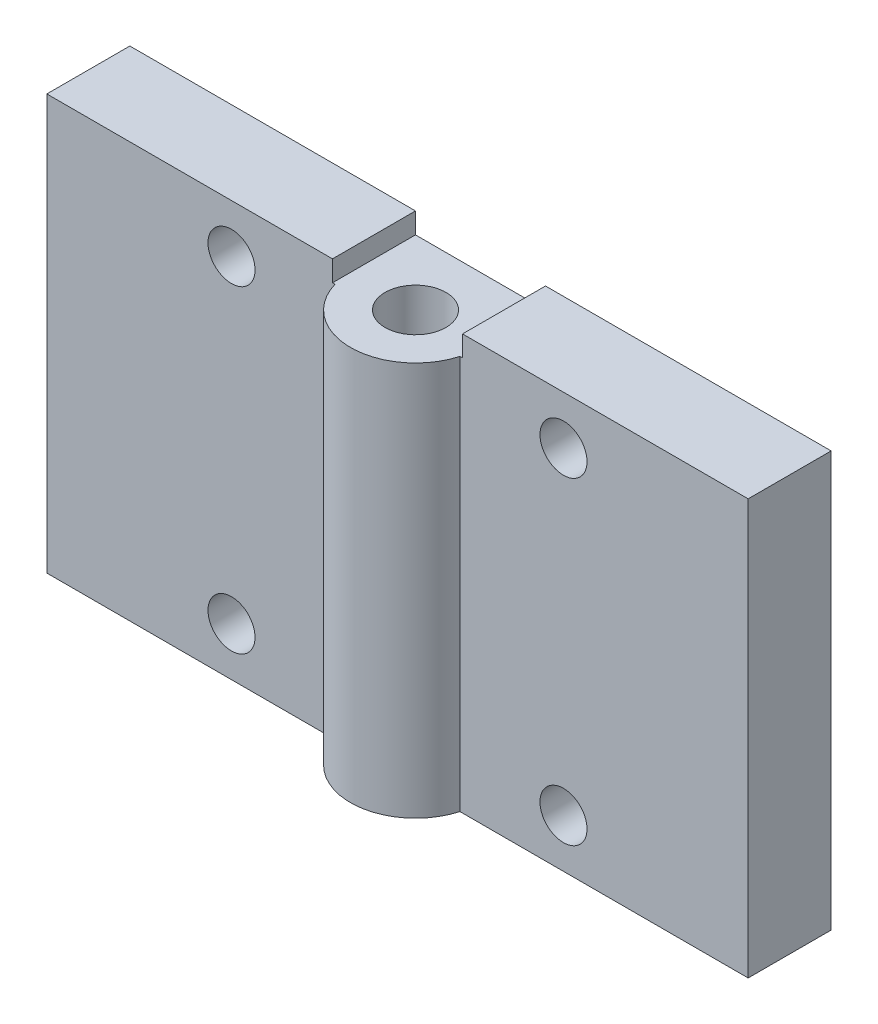
from build123d import *

# Parameters (mm, degrees)
EXTRUDE_1_DEPTH             = 28.5
SKETCH_2_W                  = 20.65
SKETCH_2_H                  = 6
EXTRUDE_2_DEPTH             = 1.5
SKETCH_3_W                  = 20.65
SKETCH_3_H                  = 6
EXTRUDE_3_DEPTH             = 1.5
HOLE_WIZARD_4_4_4_4_1_D     = 4.4
HOLE_WIZARD_4_4_4_4_1_DEPTH = 28.5
HOLE_WIZARD_3_4_3_4_1_D     = 3.4
HOLE_WIZARD_3_4_3_4_1_DEPTH = 9.4


with BuildPart() as part:
    # 草图1 → 凸台-拉伸1 (new body)
    with BuildSketch(Plane(origin=(0, 253.5, 0), x_dir=(1, 0, 0), z_dir=(0, 1, 0))):
        with BuildLine():
            Line((264.516635916, -508.1), (285.35, -508.1))
            Line((285.35, -508.1), (285.35, -502.1))
            Line((285.35, -502.1), (234.65, -502.1))
            Line((234.65, -502.1), (234.65, -508.1))
            Line((234.65, -508.1), (255.483364084, -508.1))
            ThreePointArc((255.483364084, -508.1), (260, -511.5), (264.516635916, -508.1))
        make_face()
    extrude(amount=-EXTRUDE_1_DEPTH)

    # 草图2 → 凸台-拉伸2 (add)
    with BuildSketch(Plane(origin=(0, 253.5, 0), x_dir=(-1, 0, 0), z_dir=(0, 1, 0))):
        with Locations((-275.025, 505.1)):
            Rectangle(SKETCH_2_W, SKETCH_2_H)
    extrude(amount=EXTRUDE_2_DEPTH)

    # 草图3 → 凸台-拉伸3 (add)
    with BuildSketch(Plane(origin=(0, 253.5, 0), x_dir=(-1, 0, 0), z_dir=(0, 1, 0))):
        with Locations((-244.975, 505.1)):
            Rectangle(SKETCH_3_W, SKETCH_3_H)
    extrude(amount=EXTRUDE_3_DEPTH)

    # Ø4.4 (4.4) 直径孔1
    with Locations(Plane(origin=(0, 253.5, 0), x_dir=(1, 0, 0), z_dir=(0, 1, 0))):
        with Locations((260, -506.8)):
            Hole(HOLE_WIZARD_4_4_4_4_1_D / 2, depth=HOLE_WIZARD_4_4_4_4_1_DEPTH)

    # Ø3.4 (3.4) 直径孔1
    with Locations(Plane(origin=(0, 0, 502.1), x_dir=(-1, 0, 0), z_dir=(0, 0, -1))):
        with Locations((-248, 228.5), (-248, 251.5), (-272, 251.5), (-272, 228.5)):
            Hole(HOLE_WIZARD_3_4_3_4_1_D / 2, depth=HOLE_WIZARD_3_4_3_4_1_DEPTH)


solid = part.part
